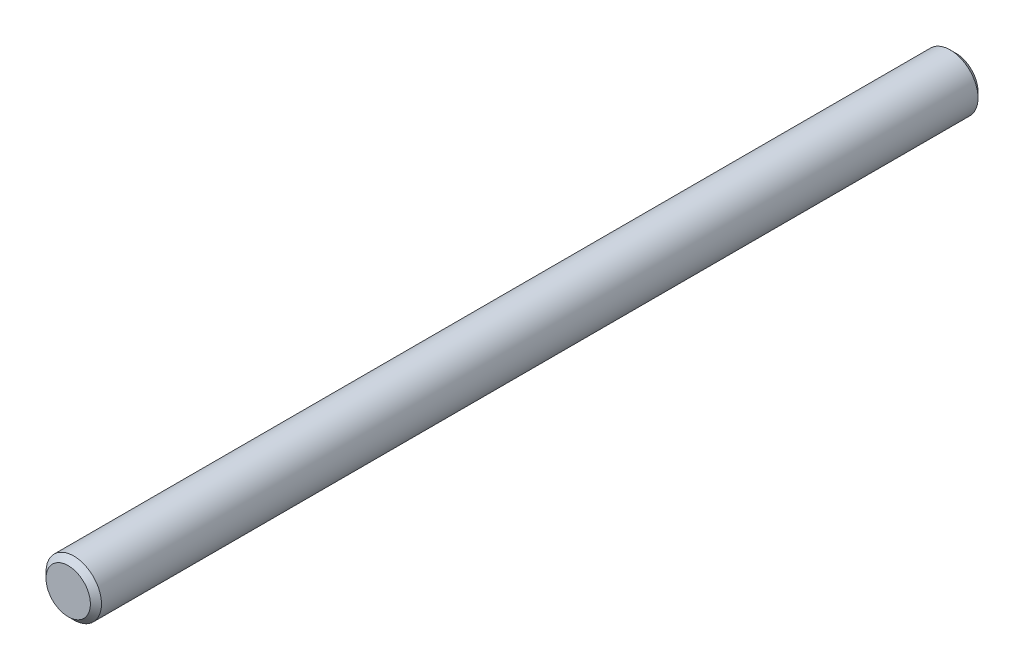
from build123d import *

# Parameters (mm, degrees)
SKETCH1_R      = 9.525
EXTRUDE1_DEPTH = 152.4
CHAMFER1_SIZE  = 1.905


with BuildPart() as part:
    # Sketch1 → Extrude1 (new body, symmetric)
    with BuildSketch(Plane.XY):
        Circle(SKETCH1_R)
    extrude(amount=EXTRUDE1_DEPTH, both=True)

    # Chamfer1
    chamfer1_edges = [part.edges().sort_by_distance(p)[0] for p in [
        (-9.525, 0, -152.4),
        (-9.525, 0, 152.4),
    ]]
    chamfer(chamfer1_edges, length=CHAMFER1_SIZE)


solid = part.part
